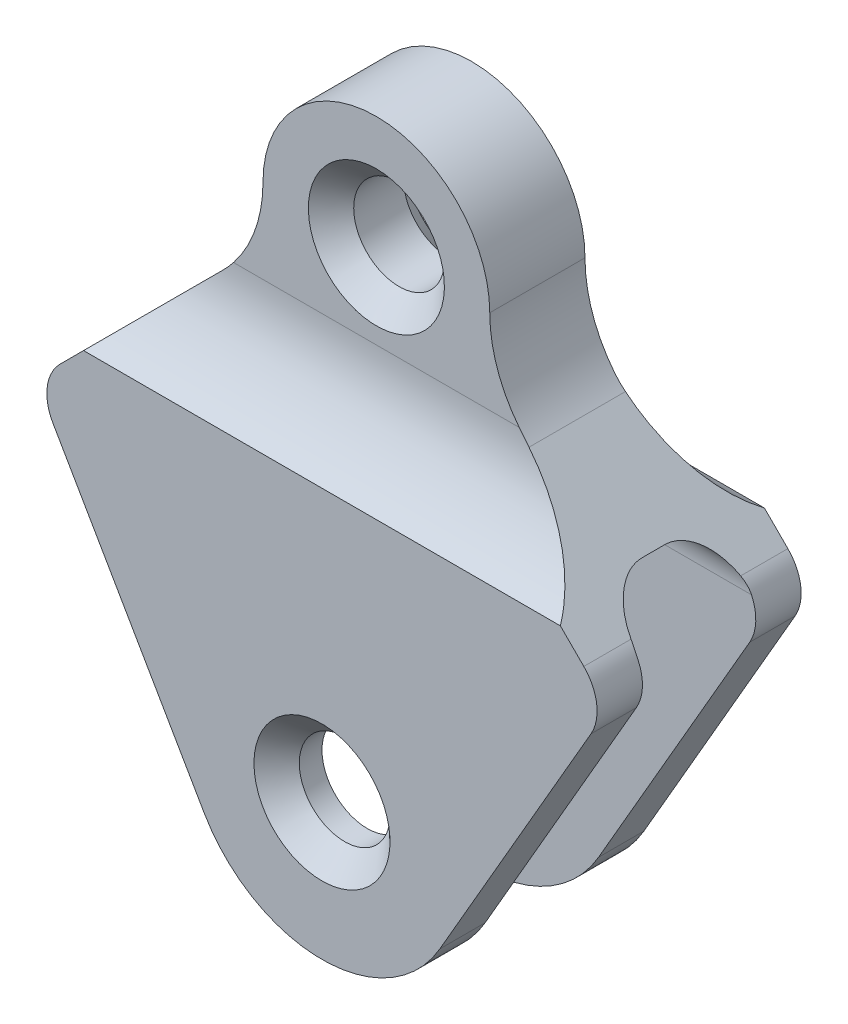
from build123d import *

# Parameters (mm, degrees)
SKETCH1_R               = 10
BOSS_EXTRUDE1_DEPTH     = 45
CUT_EXTRUDE1_DEPTH      = 61.66943013
CUT_EXTRUDE1_DEPTH_BACK = 61.66943013
CHAMFER1_SIZE           = 5


with BuildPart() as part:
    # Sketch1 → Boss-Extrude1 (new body)
    with BuildSketch(Plane.XY):
        with BuildLine():
            Line((33.786796564, -21.213203436), (57.740497942, -45.166904813))
            ThreePointArc((57.740497942, -45.166904813), (60.583878744, -50.932710702), (59.329684168, -57.237972625))
            Line((59.329684168, -57.237972625), (25.980762114, -115))
            ThreePointArc((25.980762114, -115), (0, -130), (-25.980762114, -115))
            Line((-25.980762114, -115), (-59.329684168, -57.237972625))
            ThreePointArc((-59.329684168, -57.237972625), (-60.583878744, -50.932710702), (-57.740497942, -45.166904813))
            Line((-57.740497942, -45.166904813), (-33.786796564, -21.213203436))
            ThreePointArc((-33.786796564, -21.213203436), (-27.283614025, -11.480502971), (-25, 0))
            ThreePointArc((-25, 0), (0, 25), (25, 0))
            ThreePointArc((25, 0), (27.283614025, -11.480502971), (33.786796564, -21.213203436))
        make_face()
        with Locations((0, -100)):
            Circle(SKETCH1_R, mode=Mode.SUBTRACT)
        Circle(SKETCH1_R, mode=Mode.SUBTRACT)
    extrude(amount=BOSS_EXTRUDE1_DEPTH)

    # Sketch2 → Cut-Extrude1 (cut, two sides)
    with BuildSketch(Plane(origin=(0, 0, 0), x_dir=(0, 0, -1), z_dir=(1, 0, 0))) as cut_extrude1_sk:
        with BuildLine():
            Line((-35, -130), (-35, -48))
            ThreePointArc((-35, -48), (-32.071067812, -40.928932188), (-25, -38))
            Line((-25, -38), (-20, -38))
            ThreePointArc((-20, -38), (-12.928932188, -40.928932188), (-10, -48))
            Line((-10, -48), (-10, -130))
            Line((-10, -130), (-35, -130))
        make_face()
        with BuildLine():
            Line((-12, 25), (-12, -18.645843496))
            ThreePointArc((-12, -18.645843496), (-8.794494718, -30.89329221), (0, -40))
            Line((0, -40), (0, 25))
            Line((0, 25), (-12, 25))
        make_face()
        with BuildLine():
            Line((-33, 25), (-33, -18.645843496))
            ThreePointArc((-33, -18.645843496), (-36.205505282, -30.89329221), (-45, -40))
            Line((-45, -40), (-45, 25))
            Line((-45, 25), (-33, 25))
        make_face()
    extrude(amount=CUT_EXTRUDE1_DEPTH, mode=Mode.SUBTRACT)
    extrude(cut_extrude1_sk.sketch, amount=-CUT_EXTRUDE1_DEPTH_BACK, mode=Mode.SUBTRACT)

    # Chamfer1
    chamfer1_edges = [part.edges().sort_by_distance(p)[0] for p in [
        (-10, -100, 0),
        (-10, -100, 45),
        (-10, 0, 33),
        (-10, 0, 12),
    ]]
    chamfer(chamfer1_edges, length=CHAMFER1_SIZE)


solid = part.part
